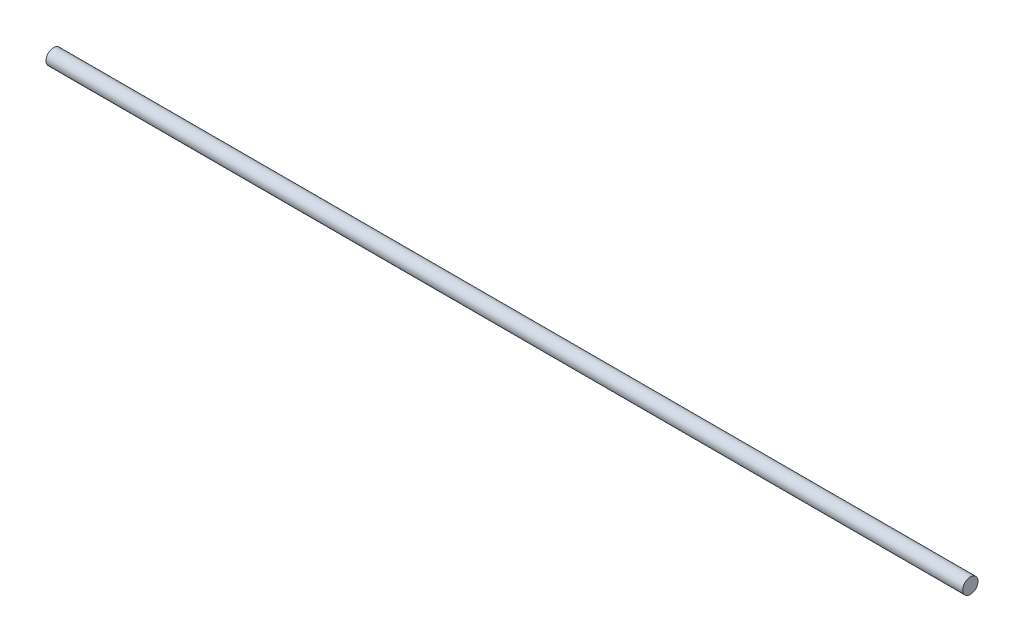
from build123d import *

# Parameters (mm, degrees)
SKETCH1_R           = 6.35
BOSS_EXTRUDE2_DEPTH = 762


with BuildPart() as part:
    # Sketch1 → Boss-Extrude2 (new body)
    with BuildSketch(Plane(origin=(0, 0, 0), x_dir=(0, 0, -1), z_dir=(1, 0, 0))):
        Circle(SKETCH1_R)
    extrude(amount=BOSS_EXTRUDE2_DEPTH)


solid = part.part
